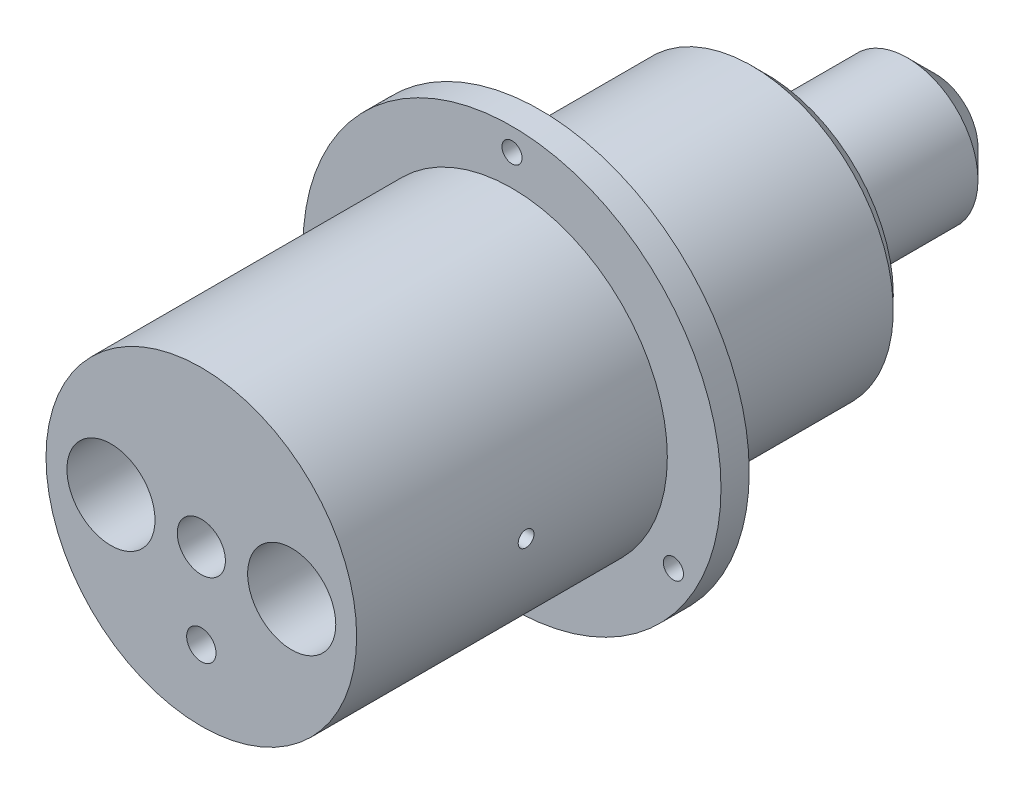
from build123d import *

# Parameters (mm, degrees)
SKETCH1_R                   = 25.4
BOSS_EXTRUDE1_DEPTH         = 38.1
BOSS_EXTRUDE1_DEPTH_BACK    = 44.45
SKETCH2_OUTSIDE_W           = 74.686
SKETCH2_OUTSIDE_H           = 74.686
SKETCH2_OUTSIDE_R           = 17.4625
CUT_EXTRUDE3_DEPTH          = 63.5
SKETCH3_R                   = 23.495
BOSS_EXTRUDE2_DEPTH         = 3.175
F_1_4_28_TAPPED_HOLE1_D     = 5.4102
F_1_4_28_TAPPED_HOLE1_DEPTH = 12.88034
F_1_4_28_TAPPED_HOLE1_TIP   = 1.625388061
SKETCH9_R                   = 0.8636
CUT_EXTRUDE4_DEPTH          = 91.02678768
SKETCH12_R                  = 4.953
CUT_EXTRUDE5_DEPTH          = 45.72
SKETCH17_R                  = 1.651
CUT_EXTRUDE7_DEPTH          = 44.45
SKETCH22_OUTSIDE_W          = 74.686
SKETCH22_OUTSIDE_H          = 74.686
SKETCH22_OUTSIDE_R          = 7.9375
CUT_EXTRUDE9_DEPTH          = 19.05
CHAMFER1_SIZE               = 3.175
F_2_56_TAPPED_HOLE3_REACH   = 81.131
F_2_56_TAPPED_HOLE3_BORE_R  = 0.889
F_2_56_TAPPED_HOLE4_REACH   = 81.131
F_2_56_TAPPED_HOLE4_BORE_R  = 0.889
CIRPATTERN1_COUNT           = 3
SKETCH25_OUTSIDE_W          = 70.184
SKETCH25_OUTSIDE_H          = 70.184
SKETCH25_OUTSIDE_R          = 15.875
CUT_EXTRUDE10_DEPTH         = 25.4


with BuildPart() as part:
    # Sketch1 → Boss-Extrude1 (new, two sides)
    with BuildSketch(Plane.XY) as boss_extrude1_sk:
        Circle(SKETCH1_R)
    extrude(amount=BOSS_EXTRUDE1_DEPTH)
    extrude(boss_extrude1_sk.sketch, amount=-BOSS_EXTRUDE1_DEPTH_BACK)

    # Sketch2 outside → Cut-Extrude3 (cut)
    with BuildSketch(Plane.XY.offset(38.1)):
        Rectangle(SKETCH2_OUTSIDE_W, SKETCH2_OUTSIDE_H)
        Circle(SKETCH2_OUTSIDE_R, mode=Mode.SUBTRACT)
    extrude(amount=-CUT_EXTRUDE3_DEPTH, mode=Mode.SUBTRACT)

    # Sketch3 → Boss-Extrude2 (add)
    with BuildSketch(Plane.XY):
        Circle(SKETCH3_R)
    extrude(amount=BOSS_EXTRUDE2_DEPTH)

    # 1/4-28 Tapped Hole1
    with Locations(Plane.XY.offset(38.1)):
        with Locations((0, 0)):
            Hole(F_1_4_28_TAPPED_HOLE1_D / 2, depth=F_1_4_28_TAPPED_HOLE1_DEPTH)
            with Locations((0, 0, -(F_1_4_28_TAPPED_HOLE1_DEPTH + F_1_4_28_TAPPED_HOLE1_TIP / 2))):  # 118° drill point
                Cone(0, F_1_4_28_TAPPED_HOLE1_D / 2, F_1_4_28_TAPPED_HOLE1_TIP, mode=Mode.SUBTRACT)

    # Sketch6 → #2 Clearance Hole1 (revolve, cut)
    with BuildSketch(Plane(origin=(0, 20.955, 3.175), x_dir=(0, -1, 0), z_dir=(1, 0, 0))):
        Polygon((0, 0), (0, 13.559492758), (1.1303, 12.88034), (1.1303, 0), align=None)
    f_2_clearance_hole1 = revolve(axis=Axis((0, 20.955, 9.525), (0, 0, -1)), mode=Mode.SUBTRACT)

    # Sketch9 → Cut-Extrude4 (cut, through all)
    with BuildSketch(Plane(origin=(0, 0, -44.45), x_dir=(-1, 0, 0), z_dir=(0, 0, -1))):
        Circle(SKETCH9_R)
    extrude(amount=-CUT_EXTRUDE4_DEPTH, mode=Mode.SUBTRACT)

    # Sketch12 → Cut-Extrude5 (cut)
    with BuildSketch(Plane.XY.offset(38.1)):
        with Locations((-10.16, 0)):
            Circle(SKETCH12_R)
        with Locations((10.16, 0)):
            Circle(SKETCH12_R)
    extrude(amount=-CUT_EXTRUDE5_DEPTH, mode=Mode.SUBTRACT)

    # Sketch17 → Cut-Extrude7 (cut)
    with BuildSketch(Plane.XY.offset(38.1)):
        with Locations((0, -9.525)):
            Circle(SKETCH17_R)
    extrude(amount=-CUT_EXTRUDE7_DEPTH, mode=Mode.SUBTRACT)

    # Sketch22 outside → Cut-Extrude9 (cut)
    with BuildSketch(Plane(origin=(0, 0, -44.45), x_dir=(-1, 0, 0), z_dir=(0, 0, -1))):
        Rectangle(SKETCH22_OUTSIDE_W, SKETCH22_OUTSIDE_H)
        Circle(SKETCH22_OUTSIDE_R, mode=Mode.SUBTRACT)
    extrude(amount=-CUT_EXTRUDE9_DEPTH, mode=Mode.SUBTRACT)

    # Chamfer1
    chamfer1_edges = [part.edges().sort_by_distance(p)[0] for p in [
        (-17.4625, 0, -25.4),
        (7.9375, 0, -44.45),
    ]]
    chamfer(chamfer1_edges, length=CHAMFER1_SIZE)

    # #2-56 Tapped Hole3 bore (on position points) → #2-56 Tapped Hole3 (cut, up to next)
    with BuildSketch(Plane(origin=(0, -17.4625, 19.05), x_dir=(-1, 0, 0), z_dir=(0, -1, 0)), mode=Mode.PRIVATE) as f_2_56_tapped_hole3_sk1:
        Circle(F_2_56_TAPPED_HOLE3_BORE_R)
    f_2_56_tapped_hole3_tool1 = extrude(f_2_56_tapped_hole3_sk1.sketch, amount=-F_2_56_TAPPED_HOLE3_REACH, mode=Mode.PRIVATE) & part.part
    add(f_2_56_tapped_hole3_tool1.solids().sort_by_distance((0, -17.4625, 19.05))[0], mode=Mode.SUBTRACT)

    # #2-56 Tapped Hole4 bore (on position points) → #2-56 Tapped Hole4 (cut, up to next)
    with BuildSketch(Plane(origin=(17.4625, 0, 19.05), x_dir=(0, 0, 1), z_dir=(1, 0, 0)), mode=Mode.PRIVATE) as f_2_56_tapped_hole4_sk1:
        Circle(F_2_56_TAPPED_HOLE4_BORE_R)
    f_2_56_tapped_hole4_tool1 = extrude(f_2_56_tapped_hole4_sk1.sketch, amount=-F_2_56_TAPPED_HOLE4_REACH, mode=Mode.PRIVATE) & part.part
    f_2_56_tapped_hole4 = f_2_56_tapped_hole4_tool1.solids().sort_by_distance((17.4625, 0, 19.05))[0]
    add(f_2_56_tapped_hole4, mode=Mode.SUBTRACT)

    # Mirror2: #2-56 Tapped Hole4 across plane
    add(f_2_56_tapped_hole4.mirror(Plane(origin=(0, 0, 0), x_dir=(0, 0, 1), z_dir=(1, 0, 0))), mode=Mode.SUBTRACT)

    # CirPattern1: #2 Clearance Hole1 ×3 about axis
    cirpattern1_axis = Axis((0, 0, 0), (0, 0, 1))
    for i in range(1, CIRPATTERN1_COUNT):
        add(f_2_clearance_hole1.rotate(cirpattern1_axis, i * 360 / CIRPATTERN1_COUNT), mode=Mode.SUBTRACT)

    # Sketch25 outside → Cut-Extrude10 (cut)
    with BuildSketch(Plane(origin=(0, 0, -25.4), x_dir=(-1, 0, 0), z_dir=(0, 0, -1))):
        Rectangle(SKETCH25_OUTSIDE_W, SKETCH25_OUTSIDE_H)
        Circle(SKETCH25_OUTSIDE_R, mode=Mode.SUBTRACT)
    extrude(amount=-CUT_EXTRUDE10_DEPTH, mode=Mode.SUBTRACT)


solid = part.part
